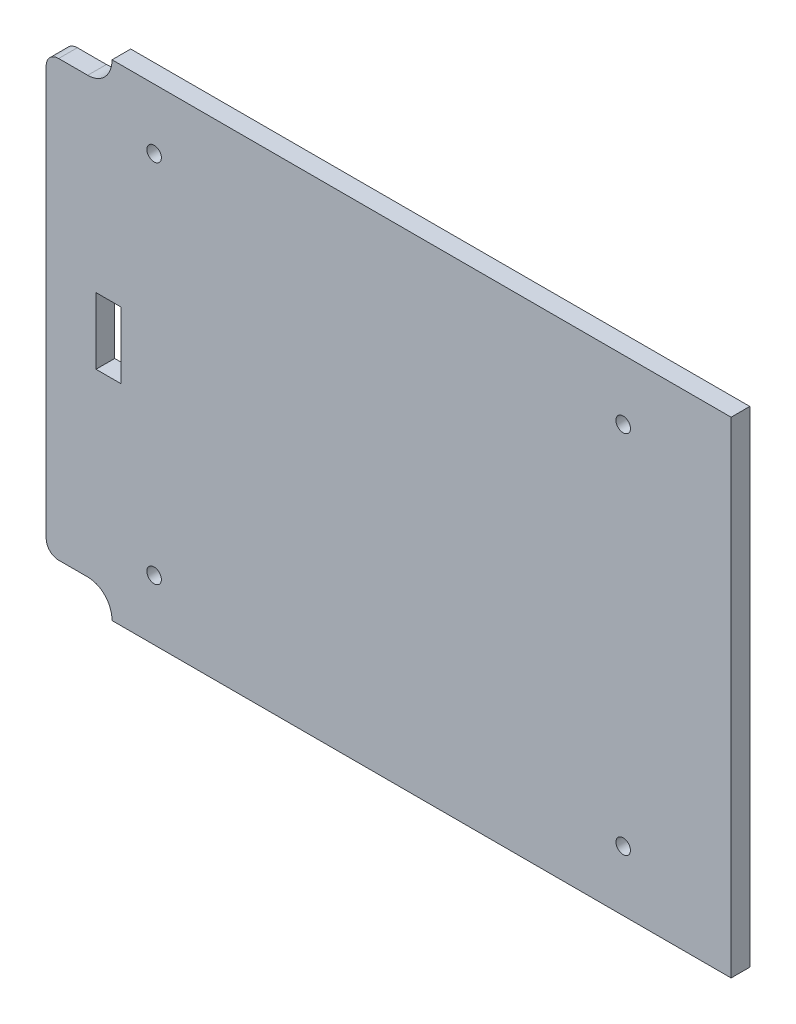
from build123d import *

# Parameters (mm, degrees)
SKETCH2_W               = 165
SKETCH2_H               = 117
BOSS_EXTRUDE1_DEPTH     = 4.5
SKETCH3_R               = 1.75
CUT_EXTRUDE1_DEPTH      = 5.5
MIRROR2_COPY_1_SKETCH_R = 1.75
MIRROR2_COPY_1_DEPTH    = 5.5
CUT_EXTRUDE2_REACH      = 6.5
SKETCH4_W               = 6
SKETCH4_H               = 16
CUT_EXTRUDE3_DEPTH      = 4.5


with BuildPart() as part:
    # Sketch2 → Boss-Extrude1 (new body)
    with BuildSketch(Plane.XY):
        Rectangle(SKETCH2_W, SKETCH2_H)
    extrude(amount=BOSS_EXTRUDE1_DEPTH)

    # Sketch3 → Cut-Extrude1 (cut, through all)
    with BuildSketch(Plane.XY.offset(4.5)):
        with Locations((-56.5, 44)):
            Circle(SKETCH3_R)
    cut_extrude1 = extrude(amount=-CUT_EXTRUDE1_DEPTH, mode=Mode.SUBTRACT)

    # Mirror1: Cut-Extrude1 across plane
    add(cut_extrude1.mirror(Plane(origin=(0, 0, 0), x_dir=(0, 0, 1), z_dir=(1, 0, 0))), mode=Mode.SUBTRACT)

    # Mirror2: Cut-Extrude1 across plane
    add(cut_extrude1.mirror(Plane.ZX), mode=Mode.SUBTRACT)

    # Mirror2 copy 1 sketch → Mirror2 copy 1 (cut, through all)
    with BuildSketch(Plane(origin=(0, 0, 4.5), x_dir=(-1, 0, 0), z_dir=(0, 0, 1))):
        with Locations((-56.5, 44)):
            Circle(MIRROR2_COPY_1_SKETCH_R)
    extrude(amount=-MIRROR2_COPY_1_DEPTH, mode=Mode.SUBTRACT)

    # Sketch4 → Cut-Extrude2 (cut, up to next)
    with BuildSketch(Plane.XY.offset(4.5), mode=Mode.PRIVATE) as cut_extrude2_sk1:
        with Locations((-67.5, 0)):
            Rectangle(SKETCH4_W, SKETCH4_H)
    cut_extrude2_tool1 = extrude(cut_extrude2_sk1.sketch, amount=-CUT_EXTRUDE2_REACH, mode=Mode.PRIVATE) & part.part
    add(cut_extrude2_tool1.solids().sort_by_distance((-67.5, 0, 4.5))[0], mode=Mode.SUBTRACT)

    # Sketch5 → Cut-Extrude3 (cut)
    with BuildSketch(Plane.XY.offset(4.5)):
        with BuildLine():
            ThreePointArc((-82.5, 49.340007913), (-81.621787101, 51.460201405), (-79.501593608, 52.338414304))
            Line((-79.501593608, 52.338414304), (-72.492625761, 52.338414304))
            ThreePointArc((-72.492625761, 52.338414304), (-69.498148124, 53.179301378), (-67.379159906, 55.456114132))
            ThreePointArc((-67.379159906, 55.456114132), (-66.828268927, 56.933959128), (-66.641125435, 58.5))
            Line((-66.641125435, 58.5), (-82.5, 58.5))
            Line((-82.5, 58.5), (-82.5, 49.340007913))
        make_face()
    cut_extrude3 = extrude(amount=-CUT_EXTRUDE3_DEPTH, mode=Mode.SUBTRACT)

    # Mirror3: Cut-Extrude3 across plane
    add(cut_extrude3.mirror(Plane.ZX), mode=Mode.SUBTRACT)


solid = part.part
